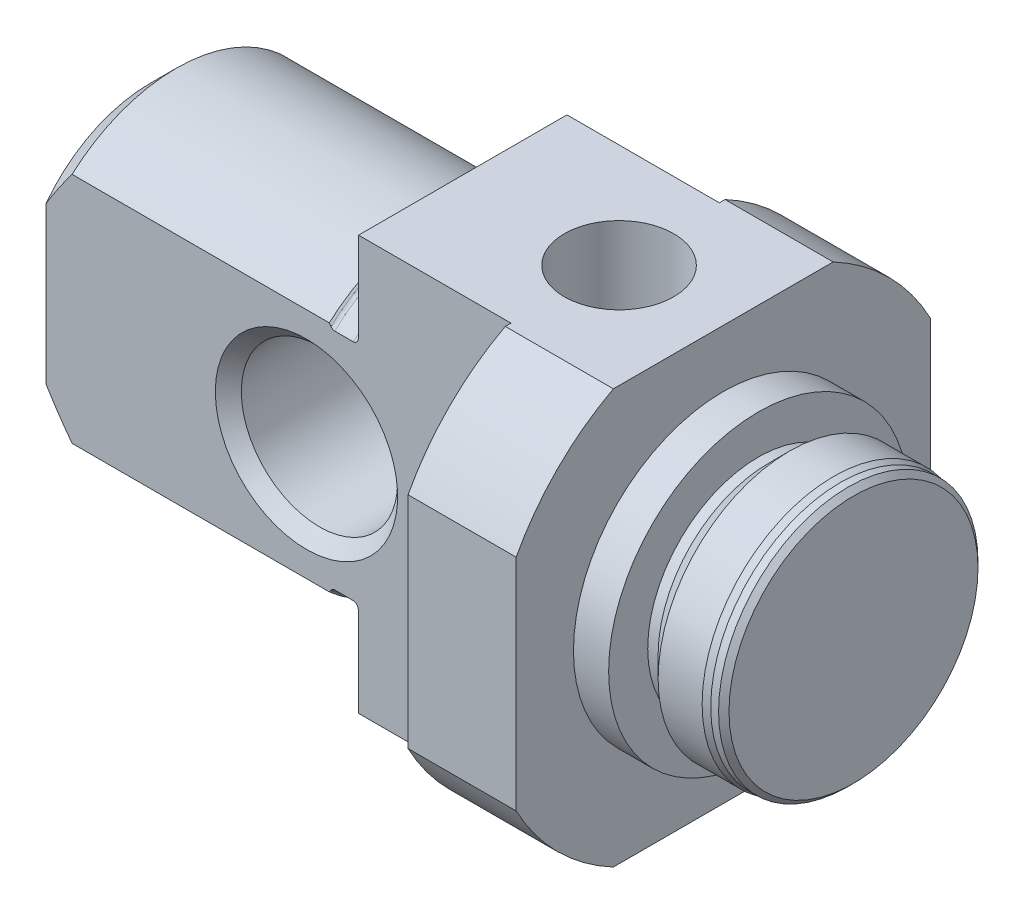
from build123d import *

# Parameters (mm, degrees)
O_L_DEPTH             = 17.85
CUT_EXTRUDE4_REACH    = 17
CUT_EXTRUDE2_REACH    = 13.95
SKETCH4_R             = 3
CHAMFER4_SIZE         = 0.5
M5_TAPPED_HOLE1_D     = 4.2
M5_TAPPED_HOLE1_DEPTH = 6
M5_TAPPED_HOLE1_TIP   = 1.212435565


with BuildPart() as part:
    # Sketch1 → Revolve1 (revolve)
    with BuildSketch(Plane.XY):
        with BuildLine():
            Line((-22, 0), (-22, 5))
            Line((-22, 5), (-21, 6))
            Line((-21, 6), (-11.125, 6))
            Line((-11.125, 6), (-11.058578644, 5.933578644))
            ThreePointArc((-11.058578644, 5.933578644), (-10.993693974, 5.890224093), (-10.917157288, 5.875))
            Line((-10.917157288, 5.875), (-10.2, 5.875))
            ThreePointArc((-10.2, 5.875), (-10.058578644, 5.933578644), (-10, 6.075))
            Line((-10, 6.075), (-10, 9))
            Line((-10, 9), (0, 9))
            Line((0, 9), (0, 5.75))
            Line((0, 5.75), (1.35, 5.75))
            Line((1.35, 5.75), (1.35, 4.25))
            Line((1.35, 4.25), (1.75, 4.25))
            Line((1.75, 4.25), (2.55, 5.05))
            Line((2.55, 5.05), (4.238756443, 5.05))
            Line((4.238756443, 5.05), (4.5, 4.98))
            Line((4.5, 4.98), (4.8, 4.98))
            Line((4.8, 4.98), (5, 4.78))
            Line((5, 4.78), (5, 0))
            Line((5, 0), (-22, 0))
        make_face()
    revolve(axis=Axis((0, 0, 0), (1, 0, 0)))

    # Sketch3 → O-L (cut)
    with BuildSketch(Plane.ZY.offset(22)):
        with BuildLine():
            Line((-4, 8.062257748), (-4, -8.062257748))
            ThreePointArc((-4, -8.062257748), (-9, 0), (-4, 8.062257748))
        make_face()
        with BuildLine():
            Line((4, 8.062257748), (4, -8.062257748))
            ThreePointArc((4, -8.062257748), (9, 0), (4, 8.062257748))
        make_face()
    extrude(amount=-O_L_DEPTH, mode=Mode.SUBTRACT)

    # Sketch6 → Cut-Extrude4 (cut, up to next)
    with BuildSketch(Plane.ZY.offset(10), mode=Mode.PRIVATE) as cut_extrude4_sk1:
        with BuildLine():
            Line((-4.218708333, 7.95), (4.218708333, 7.95))
            ThreePointArc((4.218708333, 7.95), (0, 9), (-4.218708333, 7.95))
        make_face()
    cut_extrude4_tool1 = extrude(cut_extrude4_sk1.sketch, amount=-CUT_EXTRUDE4_REACH, mode=Mode.PRIVATE) & part.part
    add(cut_extrude4_tool1.solids().sort_by_distance((-10, 8.372173, 0))[0], mode=Mode.SUBTRACT)
    # Sketch6 → Cut-Extrude4 (cut, up to next)
    with BuildSketch(Plane.ZY.offset(10), mode=Mode.PRIVATE) as cut_extrude4_sk2:
        with BuildLine():
            Line((7.95, 4.218708333), (7.95, -4.218708333))
            ThreePointArc((7.95, -4.218708333), (9, 0), (7.95, 4.218708333))
        make_face()
    cut_extrude4_tool2 = extrude(cut_extrude4_sk2.sketch, amount=-CUT_EXTRUDE4_REACH, mode=Mode.PRIVATE) & part.part
    add(cut_extrude4_tool2.solids().sort_by_distance((-10, 0, 8.372173))[0], mode=Mode.SUBTRACT)
    # Sketch6 → Cut-Extrude4 (cut, up to next)
    with BuildSketch(Plane.ZY.offset(10), mode=Mode.PRIVATE) as cut_extrude4_sk3:
        with BuildLine():
            Line((4.218708333, -7.95), (-4.218708333, -7.95))
            ThreePointArc((-4.218708333, -7.95), (0, -9), (4.218708333, -7.95))
        make_face()
    cut_extrude4_tool3 = extrude(cut_extrude4_sk3.sketch, amount=-CUT_EXTRUDE4_REACH, mode=Mode.PRIVATE) & part.part
    add(cut_extrude4_tool3.solids().sort_by_distance((-10, -8.372173, 0))[0], mode=Mode.SUBTRACT)
    # Sketch6 → Cut-Extrude4 (cut, up to next)
    with BuildSketch(Plane.ZY.offset(10), mode=Mode.PRIVATE) as cut_extrude4_sk4:
        with BuildLine():
            Line((-7.95, -4.218708333), (-7.95, 4.218708333))
            ThreePointArc((-7.95, 4.218708333), (-9, 0), (-7.95, -4.218708333))
        make_face()
    cut_extrude4_tool4 = extrude(cut_extrude4_sk4.sketch, amount=-CUT_EXTRUDE4_REACH, mode=Mode.PRIVATE) & part.part
    add(cut_extrude4_tool4.solids().sort_by_distance((-10, 0, -8.372173))[0], mode=Mode.SUBTRACT)

    # Sketch4 → Cut-Extrude2 (cut, up to next)
    with BuildSketch(Plane.XY.offset(4), mode=Mode.PRIVATE) as cut_extrude2_sk1:
        with Locations((-12, 0)):
            Circle(SKETCH4_R)
    cut_extrude2_tool1 = extrude(cut_extrude2_sk1.sketch, amount=-CUT_EXTRUDE2_REACH, mode=Mode.PRIVATE) & part.part
    add(cut_extrude2_tool1.solids().sort_by_distance((-12, 0, 4))[0], mode=Mode.SUBTRACT)

    # Chamfer4
    chamfer4_edges = [part.edges().sort_by_distance(p)[0] for p in [
        (-15, 0, 4),
        (-15, 0, -4),
    ]]
    chamfer(chamfer4_edges, length=CHAMFER4_SIZE)

    # M5 Tapped Hole1
    with Locations(Plane(origin=(0, 7.95, 0), x_dir=(1, 0, 0), z_dir=(0, 1, 0))):
        with Locations((-4, 0)):
            Hole(M5_TAPPED_HOLE1_D / 2, depth=M5_TAPPED_HOLE1_DEPTH)
            with Locations((0, 0, -(M5_TAPPED_HOLE1_DEPTH + M5_TAPPED_HOLE1_TIP / 2))):  # 120° drill point
                Cone(0, M5_TAPPED_HOLE1_D / 2, M5_TAPPED_HOLE1_TIP, mode=Mode.SUBTRACT)


solid = part.part
